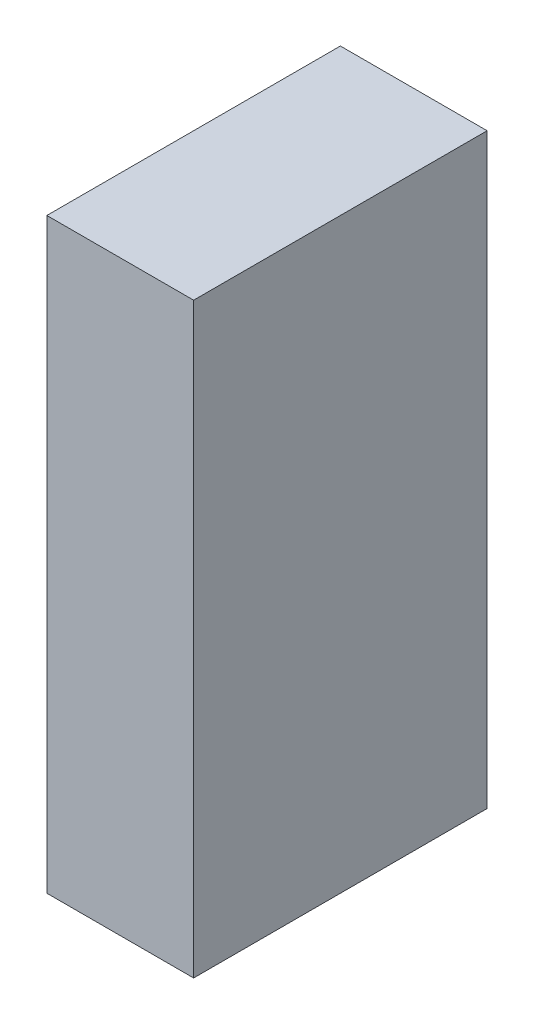
from build123d import *

# Parameters (mm, degrees)
SKETCH1_W           = 25.4
SKETCH1_H           = 50.8
BOSS_EXTRUDE1_DEPTH = 101.6


with BuildPart() as part:
    # Sketch1 → Boss-Extrude1 (new body)
    with BuildSketch(Plane(origin=(0, 0, 0), x_dir=(1, 0, 0), z_dir=(0, 1, 0))):
        Rectangle(SKETCH1_W, SKETCH1_H)
    extrude(amount=BOSS_EXTRUDE1_DEPTH)


solid = part.part
